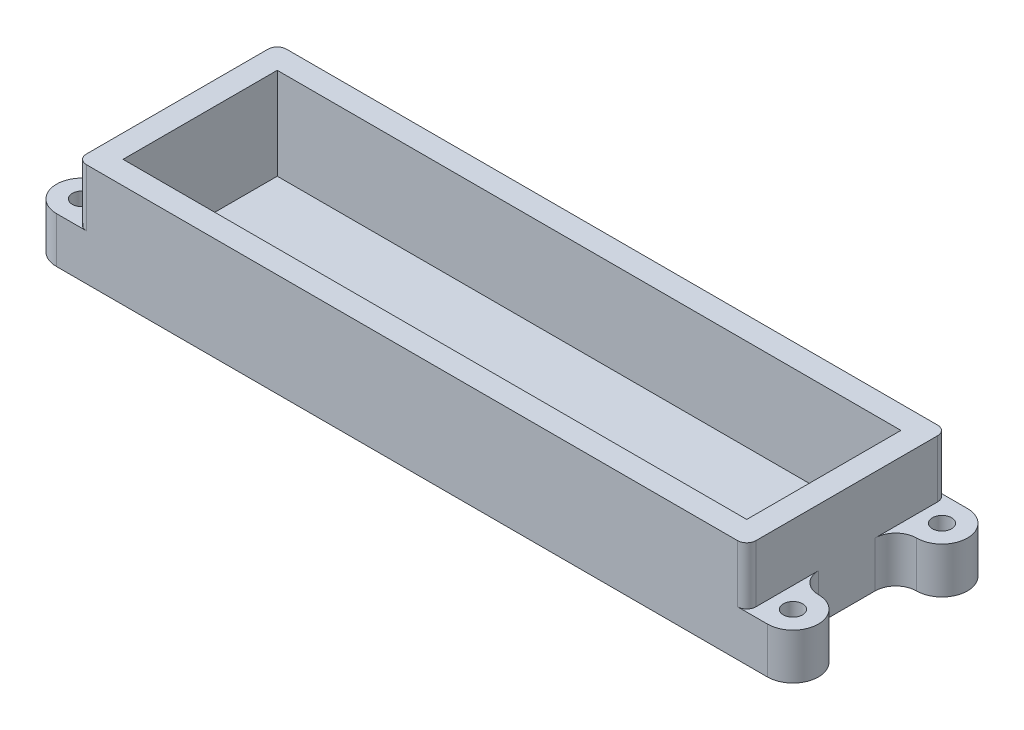
from build123d import *

# Parameters (mm, degrees)
SKETCH1_W                 = 172.7
SKETCH1_H                 = 42.7
SKETCH1_R                 = 3.175
BOSS_EXTRUDE1_DEPTH       = 3.175
BOSS_EXTRUDE2_START       = 3.175
SKETCH1_3_R               = 3.175
BOSS_EXTRUDE2_DEPTH       = 6.35
SKETCH1_4_W               = 185.4
SKETCH1_4_H               = 55.4
SKETCH1_4_W_2             = 172.7
SKETCH1_4_H_2             = 42.7
BOSS_EXTRUDE3_DEPTH       = 28.575
SKETCH1_5_R               = 2.667
BOSS_EXTRUDE4_DEPTH       = 12.7
M2X0_4_TAPPED_HOLE1_D     = 1.6
M2X0_4_TAPPED_HOLE1_DEPTH = 5.19938
M2X0_4_TAPPED_HOLE1_TIP   = 0.480688495
FILLET1_R                 = 2.54


with BuildPart() as part:
    # Sketch1 → Boss-Extrude1 (new body)
    with BuildSketch(Plane(origin=(0, 0, 0), x_dir=(1, 0, 0), z_dir=(0, 1, 0))):
        with Locations((92.7, 27.7)):
            Rectangle(SKETCH1_W, SKETCH1_H)
        with Locations((142.7, 20.7)):
            Circle(SKETCH1_R, mode=Mode.SUBTRACT)
        with Locations((42.7, 20.7)):
            Circle(SKETCH1_R, mode=Mode.SUBTRACT)
        with Locations((42.7, 20.7)):
            Circle(SKETCH1_R)
        with Locations((142.7, 20.7)):
            Circle(SKETCH1_R)
    extrude(amount=BOSS_EXTRUDE1_DEPTH)

    # Sketch1_3 → Boss-Extrude2 (add)
    with BuildSketch(Plane(origin=(0, 0, 0), x_dir=(1, 0, 0), z_dir=(0, 1, 0)).offset(BOSS_EXTRUDE2_START)):
        with Locations((42.7, 20.7)):
            Circle(SKETCH1_3_R)
        with Locations((142.7, 20.7)):
            Circle(SKETCH1_3_R)
    extrude(amount=BOSS_EXTRUDE2_DEPTH)

    # Sketch1_4 → Boss-Extrude3 (add)
    with BuildSketch(Plane(origin=(0, 0, 0), x_dir=(1, 0, 0), z_dir=(0, 1, 0))):
        with Locations((92.7, 27.7)):
            Rectangle(SKETCH1_4_W, SKETCH1_4_H)
        with Locations((92.7, 27.7)):
            Rectangle(SKETCH1_4_W_2, SKETCH1_4_H_2, mode=Mode.SUBTRACT)
    extrude(amount=BOSS_EXTRUDE3_DEPTH)

    # Sketch1_5 → Boss-Extrude4 (add)
    with BuildSketch(Plane(origin=(0, 0, 0), x_dir=(1, 0, 0), z_dir=(0, 1, 0))):
        with BuildLine():
            Line((-5.725, 0), (0, 0))
            Line((0, 0), (0, 19.85))
            ThreePointArc((0, 19.85), (-1.676813678, 15.801813678), (-5.725, 14.125))
            ThreePointArc((-5.725, 14.125), (-12.7875, 7.0625), (-5.725, 0))
        make_face()
        with Locations((-5.725, 7.0625)):
            Circle(SKETCH1_5_R, mode=Mode.SUBTRACT)
        with BuildLine():
            ThreePointArc((-5.725, 41.275), (-1.676813678, 39.598186322), (0, 35.55))
            Line((0, 35.55), (0, 55.4))
            Line((0, 55.4), (-5.725, 55.4))
            ThreePointArc((-5.725, 55.4), (-12.7875, 48.3375), (-5.725, 41.275))
        make_face()
        with Locations((-5.725, 48.3375)):
            Circle(SKETCH1_5_R, mode=Mode.SUBTRACT)
        with BuildLine():
            Line((185.4, 19.85), (185.4, 0))
            Line((185.4, 0), (191.125, 0))
            ThreePointArc((191.125, 0), (198.1875, 7.0625), (191.125, 14.125))
            ThreePointArc((191.125, 14.125), (187.076813678, 15.801813678), (185.4, 19.85))
        make_face()
        with Locations((191.125, 7.0625)):
            Circle(SKETCH1_5_R, mode=Mode.SUBTRACT)
        with BuildLine():
            Line((185.4, 55.4), (185.4, 35.55))
            ThreePointArc((185.4, 35.55), (187.076813678, 39.598186322), (191.125, 41.275))
            ThreePointArc((191.125, 41.275), (198.1875, 48.3375), (191.125, 55.4))
            Line((191.125, 55.4), (185.4, 55.4))
        make_face()
        with Locations((191.125, 48.3375)):
            Circle(SKETCH1_5_R, mode=Mode.SUBTRACT)
    extrude(amount=BOSS_EXTRUDE4_DEPTH)

    # M2x0.4 Tapped Hole1
    with Locations(Plane(origin=(0, 9.525, 0), x_dir=(1, 0, 0), z_dir=(0, 1, 0))):
        with Locations((42.7, 20.7), (142.7, 20.7)):
            Hole(M2X0_4_TAPPED_HOLE1_D / 2, depth=M2X0_4_TAPPED_HOLE1_DEPTH)
            with Locations((0, 0, -(M2X0_4_TAPPED_HOLE1_DEPTH + M2X0_4_TAPPED_HOLE1_TIP / 2))):  # 118° drill point
                Cone(0, M2X0_4_TAPPED_HOLE1_D / 2, M2X0_4_TAPPED_HOLE1_TIP, mode=Mode.SUBTRACT)

    # Fillet1
    fillet1_edges = [part.edges().sort_by_distance(p)[0] for p in [
        (0, 20.6375, -55.4),
        (185.4, 20.6375, -55.4),
        (185.4, 20.6375, 0),
        (0, 20.6375, 0),
    ]]
    fillet(fillet1_edges, radius=FILLET1_R)


solid = part.part
